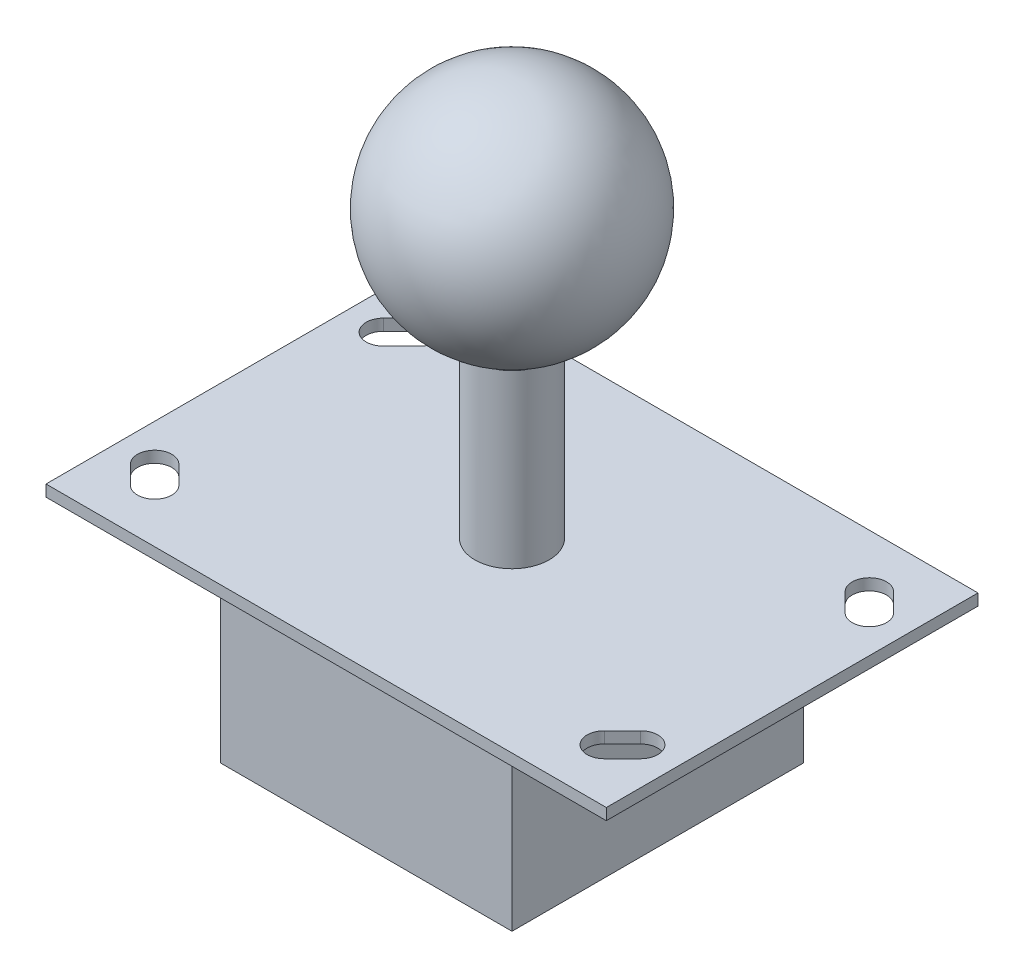
from build123d import *

# Parameters (mm, degrees)
SKETCH3_R           = 6.5
BOSS_EXTRUDE2_DEPTH = 30
SKETCH4_W           = 98
SKETCH4_H           = 65
BOSS_EXTRUDE3_DEPTH = 2
SKETCH5_W           = 51
SKETCH5_H           = 51
BOSS_EXTRUDE4_DEPTH = 32
CUT_EXTRUDE1_DEPTH  = 68.920909888


with BuildPart() as part:
    # Sketch3 → Boss-Extrude2 (new body)
    with BuildSketch(Plane(origin=(0, 0, 0), x_dir=(1, 0, 0), z_dir=(0, 1, 0))):
        with Locations(Location((0, 0, 0), (0, 0, 270))):
            Circle(SKETCH3_R)
    extrude(amount=BOSS_EXTRUDE2_DEPTH)

    # Sketch4 → Boss-Extrude3 (add)
    with BuildSketch(Plane(origin=(0, 0, 0), x_dir=(-1, 0, 0), z_dir=(0, -1, 0))):
        Rectangle(SKETCH4_W, SKETCH4_H)
    extrude(amount=BOSS_EXTRUDE3_DEPTH)

    # Sketch5 → Boss-Extrude4 (add)
    with BuildSketch(Plane.XZ.offset(2)):
        Rectangle(SKETCH5_W, SKETCH5_H)
    extrude(amount=BOSS_EXTRUDE4_DEPTH)

    # Sketch7 → Cut-Extrude1 (cut, through all)
    with BuildSketch(Plane(origin=(0, 0, 0), x_dir=(1, 0, 0), z_dir=(0, 1, 0))):
        with BuildLine():
            Line((-44.621320344, 22.121320344), (-41.439339828, 25.303300859))
            ThreePointArc((-41.439339828, 25.303300859), (-37.196699141, 25.303300859), (-37.196699141, 21.060660172))
            Line((-37.196699141, 21.060660172), (-40.378679656, 17.878679656))
            ThreePointArc((-40.378679656, 17.878679656), (-44.621320344, 17.878679656), (-44.621320344, 22.121320344))
        make_face()
        with BuildLine():
            Line((-44.621320344, -22.121320344), (-41.439339828, -25.303300859))
            ThreePointArc((-41.439339828, -25.303300859), (-37.196699141, -25.303300859), (-37.196699141, -21.060660172))
            Line((-37.196699141, -21.060660172), (-40.378679656, -17.878679656))
            ThreePointArc((-40.378679656, -17.878679656), (-44.621320344, -17.878679656), (-44.621320344, -22.121320344))
        make_face()
        with BuildLine():
            Line((40.378679656, -17.878679656), (37.196699141, -21.060660172))
            ThreePointArc((37.196699141, -21.060660172), (37.196699141, -25.303300859), (41.439339828, -25.303300859))
            Line((41.439339828, -25.303300859), (44.621320344, -22.121320344))
            ThreePointArc((44.621320344, -22.121320344), (44.621320344, -17.878679656), (40.378679656, -17.878679656))
        make_face()
        with BuildLine():
            Line((44.621320344, 22.121320344), (41.439339828, 25.303300859))
            ThreePointArc((41.439339828, 25.303300859), (37.196699141, 25.303300859), (37.196699141, 21.060660172))
            Line((37.196699141, 21.060660172), (40.378679656, 17.878679656))
            ThreePointArc((40.378679656, 17.878679656), (44.621320344, 17.878679656), (44.621320344, 22.121320344))
        make_face()
    extrude(amount=-CUT_EXTRUDE1_DEPTH, mode=Mode.SUBTRACT)


with BuildPart() as body_2:
    # 3DSketch1 → Revolve3 (revolve)
    with BuildSketch(Plane(origin=(0, 70, 0), x_dir=(0, -1, 0), z_dir=(-1, 0, 0))):
        with BuildLine():
            Line((0, 0), (40, 0))
            ThreePointArc((40, 0), (20, 20), (0, 0))
        make_face()
    revolve(axis=Axis((0, 30, 0), (0, 1, 0)))


solid = Compound([part.part, body_2.part])
